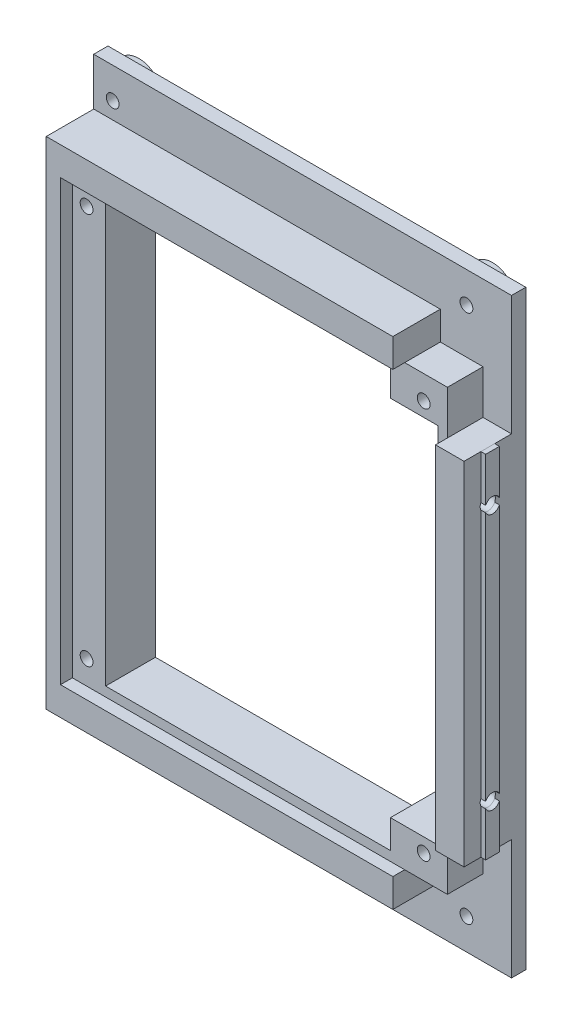
from build123d import *

# Parameters (mm, degrees)
MAIN_SKETCH_W                = 88
MAIN_SKETCH_H                = 124.5
MAIN_EXTRUSION_DEPTH         = 13
FIX_SKETCH_R                 = 5
FIX_SKETCH_R_2               = 1.35
BOARD_PLOT_DEPTH             = 2.5
ESQUISSE1_R                  = 1.35
BOARD_PLOT_HOLE_DEPTH        = 14
ESQUISSE2_W                  = 1
ESQUISSE2_H                  = 2.9
MAKERBEAM_FIXING_DEPTH       = 37
MAKERBEAM_FIXING_2_DEPTH     = 37
WINDOW_HOLE_DEPTH            = 16.5
EXTERNAL_HOLE_DEPTH          = 10
MAKERBEAM_START              = -9
ESQUISSE5_R                  = 1.6
MAKERBEAM_FIXING_HOLE_DEPTH  = 9
ESQUISSE7_W                  = 79
ESQUISSE7_H                  = 92.5
GLASS_HOLE_DEPTH             = 2.5
ESQUISSE8_R                  = 1.35
GLASS_FIXING_HOLE_DEPTH      = 3.5
GLASS_FIXING_HOLE_DEPTH_BACK = 14


with BuildPart() as part:
    # Main-Sketch → Main-Extrusion (new body)
    with BuildSketch(Plane.XY):
        Rectangle(MAIN_SKETCH_W, MAIN_SKETCH_H)
    extrude(amount=MAIN_EXTRUSION_DEPTH)

    # Fix-Sketch → Board Plot (add)
    with BuildSketch(Plane.XY):
        with Locations((-40, 55.75)):
            Circle(FIX_SKETCH_R)
        with Locations((-40, 55.75)):
            Circle(FIX_SKETCH_R_2, mode=Mode.SUBTRACT)
        with Locations((34.5, 55.75)):
            Circle(FIX_SKETCH_R)
        with Locations((34.5, 55.75)):
            Circle(FIX_SKETCH_R_2, mode=Mode.SUBTRACT)
        with Locations((34.5, -55.75)):
            Circle(FIX_SKETCH_R)
        with Locations((34.5, -55.75)):
            Circle(FIX_SKETCH_R_2, mode=Mode.SUBTRACT)
        with Locations((-40, -55.75)):
            Circle(FIX_SKETCH_R)
        with Locations((-40, -55.75)):
            Circle(FIX_SKETCH_R_2, mode=Mode.SUBTRACT)
        with Locations((12.5, -55.75)):
            Circle(FIX_SKETCH_R)
        with Locations((12.5, -55.75)):
            Circle(FIX_SKETCH_R_2, mode=Mode.SUBTRACT)
    extrude(amount=-BOARD_PLOT_DEPTH)

    # Esquisse1 → Board Plot Hole (cut, through all)
    with BuildSketch(Plane(origin=(0, 0, 0), x_dir=(-1, 0, 0), z_dir=(0, 0, -1))):
        with Locations((-34.5, 55.75)):
            Circle(ESQUISSE1_R)
        with Locations((40, 55.75)):
            Circle(ESQUISSE1_R)
        with Locations((40, -55.75)):
            Circle(ESQUISSE1_R)
        with Locations((-12.5, -55.75)):
            Circle(ESQUISSE1_R)
        with Locations((-34.5, -55.75)):
            Circle(ESQUISSE1_R)
    extrude(amount=-BOARD_PLOT_HOLE_DEPTH, mode=Mode.SUBTRACT)

    # Esquisse3 → Window Hole (cut, through all)
    with BuildSketch(Plane.XY.offset(13)):
        Polygon((-34, 44.25), (26, 44.25), (26, 38.25), (36, 38.25), (36, -38.25), (26, -38.25), (26, -44.25), (-34, -44.25), align=None)
    extrude(amount=-WINDOW_HOLE_DEPTH, mode=Mode.SUBTRACT)

    # Esquisse4 → External Hole (cut)
    with BuildSketch(Plane.XY.offset(13)):
        Polygon((44, 62.25), (44, 37), (38, 37), (38, 46.25), (29, 46.25), (29, 52.25), (-44, 52.25), (-44, 62.25), align=None)
        Polygon((44, -62.25), (44, -37), (38, -37), (38, -46.25), (29, -46.25), (29, -52.25), (-44, -52.25), (-44, -62.25), align=None)
    extrude(amount=-EXTERNAL_HOLE_DEPTH, mode=Mode.SUBTRACT)


with BuildPart() as body_2:
    # Esquisse2 → MakerBeam Fixing (new body, symmetric)
    with BuildSketch(Plane.XZ):
        with Locations((44.5, 8)):
            Rectangle(ESQUISSE2_W, ESQUISSE2_H)
    extrude(amount=MAKERBEAM_FIXING_DEPTH, both=True)


with BuildPart() as body_3:
    # Esquisse2 → MakerBeam Fixing 2 (new body, symmetric)
    with BuildSketch(Plane.XZ):
        with Locations((-44.5, 8)):
            Rectangle(ESQUISSE2_W, ESQUISSE2_H)
    extrude(amount=MAKERBEAM_FIXING_2_DEPTH, both=True)


with BuildPart() as makerbeam_fixing_hole_tool:
    # Esquisse5 → MakerBeam Fixing Hole (new body)
    with BuildSketch(Plane(origin=(45, 0, 0), x_dir=(0, 0, -1), z_dir=(1, 0, 0)).offset(MAKERBEAM_START)):
        with Locations((-8, 27)):
            Circle(ESQUISSE5_R)
        with Locations((-8, -27)):
            Circle(ESQUISSE5_R)
    extrude(amount=MAKERBEAM_FIXING_HOLE_DEPTH)


with BuildPart() as part_1:
    add(part.part)

    # MakerBeam Fixing Hole: cut by makerbeam_fixing_hole_tool
    add(makerbeam_fixing_hole_tool.part, mode=Mode.SUBTRACT)

    # Esquisse7 → Glass Hole (cut)
    with BuildSketch(Plane.XY.offset(13)):
        with Locations((-1.5, 0)):
            Rectangle(ESQUISSE7_W, ESQUISSE7_H)
    extrude(amount=-GLASS_HOLE_DEPTH, mode=Mode.SUBTRACT)

    # Esquisse8 → Glass Fixing Hole (cut, two sides)
    with BuildSketch(Plane.XY.offset(10.5)) as glass_fixing_hole_sk:
        with Locations((-38, 41.25)):
            Circle(ESQUISSE8_R)
        with Locations((33, 41.25)):
            Circle(ESQUISSE8_R)
        with Locations((33, -41.25)):
            Circle(ESQUISSE8_R)
        with Locations((-38, -41.25)):
            Circle(ESQUISSE8_R)
    extrude(amount=GLASS_FIXING_HOLE_DEPTH, mode=Mode.SUBTRACT)
    extrude(glass_fixing_hole_sk.sketch, amount=-GLASS_FIXING_HOLE_DEPTH_BACK, mode=Mode.SUBTRACT)


with BuildPart() as body_2_1:
    add(body_2.part)

    # MakerBeam Fixing Hole: cut by makerbeam_fixing_hole_tool
    add(makerbeam_fixing_hole_tool.part, mode=Mode.SUBTRACT)


solid = Compound([body_3.part, part_1.part, body_2_1.part])
